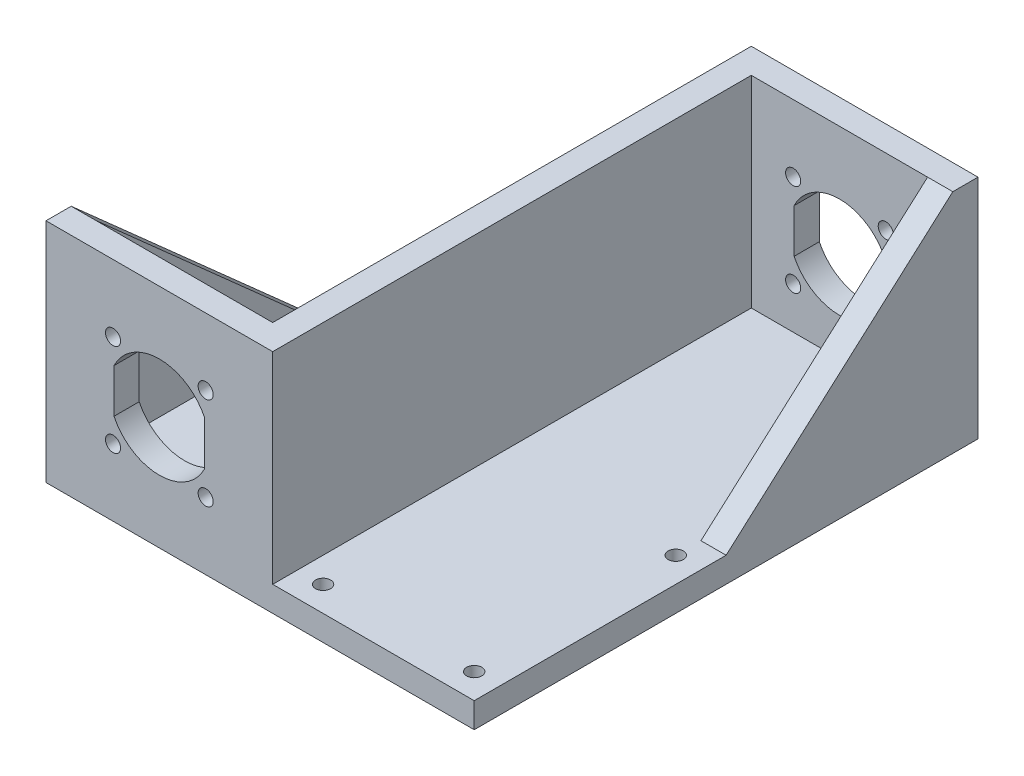
from build123d import *

# Parameters (mm, degrees)
ESQUISSE1_W             = 45
ESQUISSE1_H             = 45
ESQUISSE1_R             = 1.5
EXTRUSION1_DEPTH        = 5
ESQUISSE2_W             = 45
ESQUISSE2_H             = 5
EXTRUSION2_DEPTH        = 95
EXTRUSION3_DEPTH        = 5
ESQUISSE4_W             = 95
ESQUISSE4_H             = 40
EXTRUSION4_DEPTH        = 5
ESQUISSE5_W             = 100
ESQUISSE5_H             = 5
EXTRUSION5_DEPTH        = 40
ESQUISSE6_W             = 40
ESQUISSE6_H             = 40
EXTRUSION6_DEPTH        = 5
EXTRUSION7_DEPTH        = 5
ENL_V_MAT_EXTRU_1_REACH = 102
ESQUISSE8_R             = 1.5
ENL_V_MAT_EXTRU_2_REACH = 7
ESQUISSE9_R             = 1.5


with BuildPart() as part:
    # Esquisse1 → Extrusion1 (new body)
    with BuildSketch(Plane.XY):
        with Locations((22.5, 22.5)):
            Rectangle(ESQUISSE1_W, ESQUISSE1_H)
        with Locations((31.692388155, 31.692388155)):
            Circle(ESQUISSE1_R, mode=Mode.SUBTRACT)
        with Locations((31.692388155, 13.307611845)):
            Circle(ESQUISSE1_R, mode=Mode.SUBTRACT)
        with Locations((13.307611845, 13.307611845)):
            Circle(ESQUISSE1_R, mode=Mode.SUBTRACT)
        with Locations((13.307611845, 31.692388155)):
            Circle(ESQUISSE1_R, mode=Mode.SUBTRACT)
        with BuildLine():
            Line((13.5, 26.858898944), (13.5, 18.141101056))
            ThreePointArc((13.5, 18.141101056), (22.5, 12.5), (31.5, 18.141101056))
            Line((31.5, 18.141101056), (31.5, 26.858898944))
            ThreePointArc((31.5, 26.858898944), (22.5, 32.5), (13.5, 26.858898944))
        make_face(mode=Mode.SUBTRACT)
    extrude(amount=EXTRUSION1_DEPTH)

    # Esquisse2 → Extrusion2 (add)
    with BuildSketch(Plane.XY.offset(5)):
        with Locations((22.5, 2.5)):
            Rectangle(ESQUISSE2_W, ESQUISSE2_H)
    extrude(amount=EXTRUSION2_DEPTH)

    # Esquisse3 → Extrusion3 (add)
    with BuildSketch(Plane(origin=(45, 0, 0), x_dir=(0, 0, -1), z_dir=(1, 0, 0))):
        Polygon((-5, 5), (-5, 45), (-50, 5), align=None)
    extrude(amount=-EXTRUSION3_DEPTH)

    # Esquisse4 → Extrusion4 (add)
    with BuildSketch(Plane.ZY):
        with Locations((52.5, 25)):
            Rectangle(ESQUISSE4_W, ESQUISSE4_H)
    extrude(amount=-EXTRUSION4_DEPTH)

    # Esquisse5 → Extrusion5 (add)
    with BuildSketch(Plane.ZY):
        with Locations((50, 2.5)):
            Rectangle(ESQUISSE5_W, ESQUISSE5_H)
    extrude(amount=EXTRUSION5_DEPTH)

    # Esquisse6 → Extrusion6 (add)
    with BuildSketch(Plane.XY.offset(100)):
        with Locations((-20, 25)):
            Rectangle(ESQUISSE6_W, ESQUISSE6_H)
    extrude(amount=-EXTRUSION6_DEPTH)

    # Esquisse7 → Extrusion7 (add)
    with BuildSketch(Plane.ZY.offset(40)):
        Polygon((95, 5), (95, 45), (50, 5), align=None)
    extrude(amount=-EXTRUSION7_DEPTH)

    # Esquisse8 → Enlèv. mat.-Extru.1 (cut, up to next)
    with BuildSketch(Plane.XY.offset(100), mode=Mode.PRIVATE) as enl_v_mat_extru_1_sk1:
        with Locations((-26.692388155, 31.692388155)):
            Circle(ESQUISSE8_R)
    enl_v_mat_extru_1_tool1 = extrude(enl_v_mat_extru_1_sk1.sketch, amount=-ENL_V_MAT_EXTRU_1_REACH, mode=Mode.PRIVATE) & part.part
    add(enl_v_mat_extru_1_tool1.solids().sort_by_distance((-26.692388, 31.692388, 100))[0], mode=Mode.SUBTRACT)
    # Esquisse8 → Enlèv. mat.-Extru.1 (cut, up to next)
    with BuildSketch(Plane.XY.offset(100), mode=Mode.PRIVATE) as enl_v_mat_extru_1_sk2:
        with Locations((-26.692388155, 13.307611845)):
            Circle(ESQUISSE8_R)
    enl_v_mat_extru_1_tool2 = extrude(enl_v_mat_extru_1_sk2.sketch, amount=-ENL_V_MAT_EXTRU_1_REACH, mode=Mode.PRIVATE) & part.part
    add(enl_v_mat_extru_1_tool2.solids().sort_by_distance((-26.692388, 13.307612, 100))[0], mode=Mode.SUBTRACT)
    # Esquisse8 → Enlèv. mat.-Extru.1 (cut, up to next)
    with BuildSketch(Plane.XY.offset(100), mode=Mode.PRIVATE) as enl_v_mat_extru_1_sk3:
        with Locations((-8.307611845, 13.307611845)):
            Circle(ESQUISSE8_R)
    enl_v_mat_extru_1_tool3 = extrude(enl_v_mat_extru_1_sk3.sketch, amount=-ENL_V_MAT_EXTRU_1_REACH, mode=Mode.PRIVATE) & part.part
    add(enl_v_mat_extru_1_tool3.solids().sort_by_distance((-8.307612, 13.307612, 100))[0], mode=Mode.SUBTRACT)
    # Esquisse8 → Enlèv. mat.-Extru.1 (cut, up to next)
    with BuildSketch(Plane.XY.offset(100), mode=Mode.PRIVATE) as enl_v_mat_extru_1_sk4:
        with Locations((-8.307611845, 31.692388155)):
            Circle(ESQUISSE8_R)
    enl_v_mat_extru_1_tool4 = extrude(enl_v_mat_extru_1_sk4.sketch, amount=-ENL_V_MAT_EXTRU_1_REACH, mode=Mode.PRIVATE) & part.part
    add(enl_v_mat_extru_1_tool4.solids().sort_by_distance((-8.307612, 31.692388, 100))[0], mode=Mode.SUBTRACT)
    # Esquisse8 → Enlèv. mat.-Extru.1 (cut, up to next)
    with BuildSketch(Plane.XY.offset(100), mode=Mode.PRIVATE) as enl_v_mat_extru_1_sk5:
        with BuildLine():
            Line((-26.5, 18.141101056), (-26.5, 26.858898944))
            ThreePointArc((-26.5, 26.858898944), (-17.5, 32.5), (-8.5, 26.858898944))
            Line((-8.5, 26.858898944), (-8.5, 18.141101056))
            ThreePointArc((-8.5, 18.141101056), (-17.5, 12.5), (-26.5, 18.141101056))
        make_face()
    enl_v_mat_extru_1_tool5 = extrude(enl_v_mat_extru_1_sk5.sketch, amount=-ENL_V_MAT_EXTRU_1_REACH, mode=Mode.PRIVATE) & part.part
    add(enl_v_mat_extru_1_tool5.solids().sort_by_distance((-17.5, 22.5, 100))[0], mode=Mode.SUBTRACT)

    # Esquisse9 → Enlèv. mat.-Extru.2 (cut, up to next)
    with BuildSketch(Plane(origin=(0, 5, 0), x_dir=(-1, 0, 0), z_dir=(0, 1, 0)), mode=Mode.PRIVATE) as enl_v_mat_extru_2_sk1:
        with Locations((-40, 95)):
            Circle(ESQUISSE9_R)
    enl_v_mat_extru_2_tool1 = extrude(enl_v_mat_extru_2_sk1.sketch, amount=-ENL_V_MAT_EXTRU_2_REACH, mode=Mode.PRIVATE) & part.part
    add(enl_v_mat_extru_2_tool1.solids().sort_by_distance((40, 5, 95))[0], mode=Mode.SUBTRACT)
    # Esquisse9 → Enlèv. mat.-Extru.2 (cut, up to next)
    with BuildSketch(Plane(origin=(0, 5, 0), x_dir=(-1, 0, 0), z_dir=(0, 1, 0)), mode=Mode.PRIVATE) as enl_v_mat_extru_2_sk2:
        with Locations((-10, 95)):
            Circle(ESQUISSE9_R)
    enl_v_mat_extru_2_tool2 = extrude(enl_v_mat_extru_2_sk2.sketch, amount=-ENL_V_MAT_EXTRU_2_REACH, mode=Mode.PRIVATE) & part.part
    add(enl_v_mat_extru_2_tool2.solids().sort_by_distance((10, 5, 95))[0], mode=Mode.SUBTRACT)
    # Esquisse9 → Enlèv. mat.-Extru.2 (cut, up to next)
    with BuildSketch(Plane(origin=(0, 5, 0), x_dir=(-1, 0, 0), z_dir=(0, 1, 0)), mode=Mode.PRIVATE) as enl_v_mat_extru_2_sk3:
        with Locations((35, 5)):
            Circle(ESQUISSE9_R)
    enl_v_mat_extru_2_tool3 = extrude(enl_v_mat_extru_2_sk3.sketch, amount=-ENL_V_MAT_EXTRU_2_REACH, mode=Mode.PRIVATE) & part.part
    add(enl_v_mat_extru_2_tool3.solids().sort_by_distance((-35, 5, 5))[0], mode=Mode.SUBTRACT)
    # Esquisse9 → Enlèv. mat.-Extru.2 (cut, up to next)
    with BuildSketch(Plane(origin=(0, 5, 0), x_dir=(-1, 0, 0), z_dir=(0, 1, 0)), mode=Mode.PRIVATE) as enl_v_mat_extru_2_sk4:
        with Locations((5, 5)):
            Circle(ESQUISSE9_R)
    enl_v_mat_extru_2_tool4 = extrude(enl_v_mat_extru_2_sk4.sketch, amount=-ENL_V_MAT_EXTRU_2_REACH, mode=Mode.PRIVATE) & part.part
    add(enl_v_mat_extru_2_tool4.solids().sort_by_distance((-5, 5, 5))[0], mode=Mode.SUBTRACT)
    # Esquisse9 → Enlèv. mat.-Extru.2 (cut, up to next)
    with BuildSketch(Plane(origin=(0, 5, 0), x_dir=(-1, 0, 0), z_dir=(0, 1, 0)), mode=Mode.PRIVATE) as enl_v_mat_extru_2_sk5:
        with Locations((-40, 55)):
            Circle(ESQUISSE9_R)
    enl_v_mat_extru_2_tool5 = extrude(enl_v_mat_extru_2_sk5.sketch, amount=-ENL_V_MAT_EXTRU_2_REACH, mode=Mode.PRIVATE) & part.part
    add(enl_v_mat_extru_2_tool5.solids().sort_by_distance((40, 5, 55))[0], mode=Mode.SUBTRACT)
    # Esquisse9 → Enlèv. mat.-Extru.2 (cut, up to next)
    with BuildSketch(Plane(origin=(0, 5, 0), x_dir=(-1, 0, 0), z_dir=(0, 1, 0)), mode=Mode.PRIVATE) as enl_v_mat_extru_2_sk6:
        with Locations((35, 45)):
            Circle(ESQUISSE9_R)
    enl_v_mat_extru_2_tool6 = extrude(enl_v_mat_extru_2_sk6.sketch, amount=-ENL_V_MAT_EXTRU_2_REACH, mode=Mode.PRIVATE) & part.part
    add(enl_v_mat_extru_2_tool6.solids().sort_by_distance((-35, 5, 45))[0], mode=Mode.SUBTRACT)


solid = part.part
